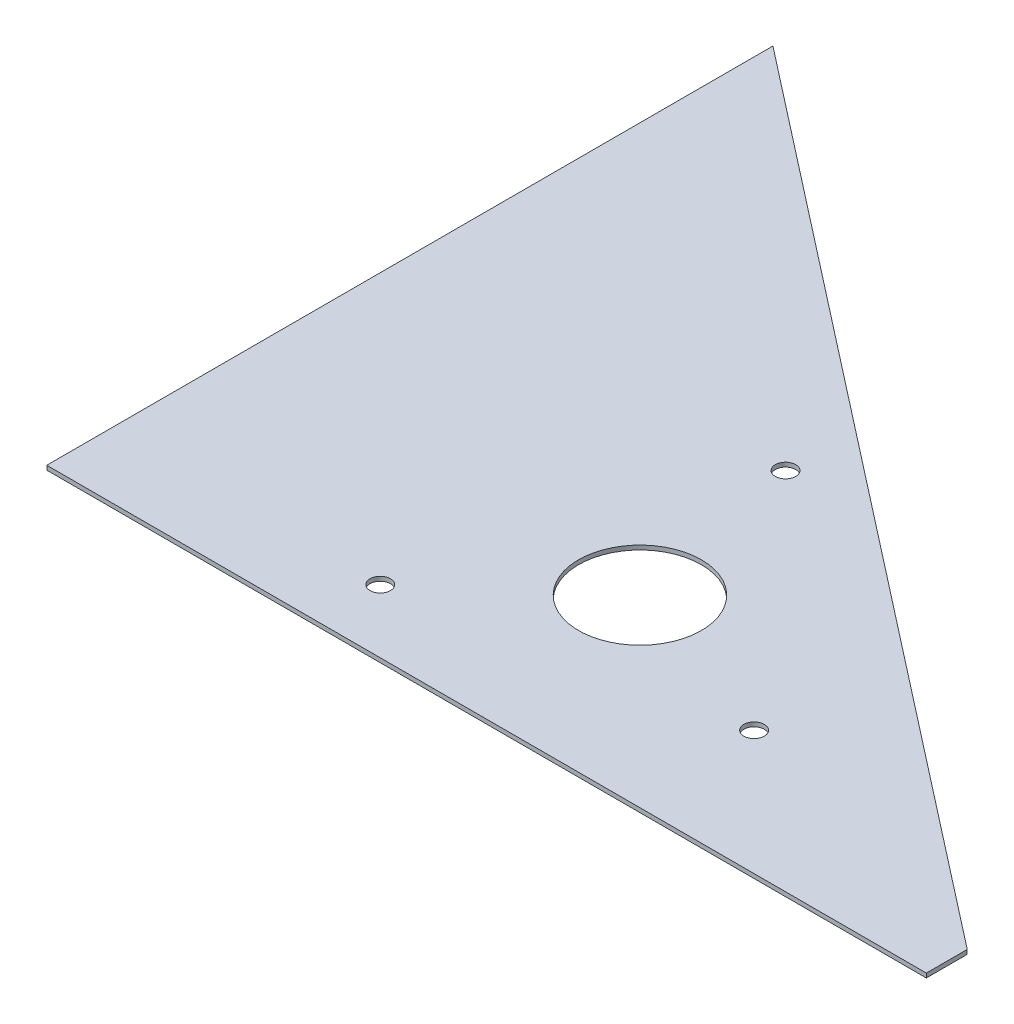
from build123d import *

# Parameters (mm, degrees)
BOSS_EXTRUDE1_DEPTH = 2.65684
SKETCH2_R           = 38.1
CUT_EXTRUDE1_DEPTH  = 3.65684
SKETCH3_R           = 6.35
CUT_EXTRUDE2_DEPTH  = 3.65684


with BuildPart() as part:
    # Sketch1 → Boss-Extrude1 (new body)
    with BuildSketch(Plane(origin=(0, 0, 0), x_dir=(1, 0, 0), z_dir=(0, 1, 0))):
        Polygon((0, 450.85), (0, 0), (546.1, 0), (546.1, 25.4), align=None)
    extrude(amount=BOSS_EXTRUDE1_DEPTH)

    # Sketch2 → Cut-Extrude1 (cut, through all)
    with BuildSketch(Plane.XZ):
        with Locations((254, -114.3)):
            Circle(SKETCH2_R)
    extrude(amount=-CUT_EXTRUDE1_DEPTH, mode=Mode.SUBTRACT)

    # Sketch3 → Cut-Extrude2 (cut, through all)
    with BuildSketch(Plane(origin=(0, 2.65684, 0), x_dir=(1, 0, 0), z_dir=(0, 1, 0))):
        with Locations((362.072773191, 77.087559946)):
            Circle(SKETCH3_R)
        with Locations((167.736694981, 39.312452986)):
            Circle(SKETCH3_R)
        with Locations((232.190531828, 226.499987068)):
            Circle(SKETCH3_R)
    extrude(amount=-CUT_EXTRUDE2_DEPTH, mode=Mode.SUBTRACT)


solid = part.part
